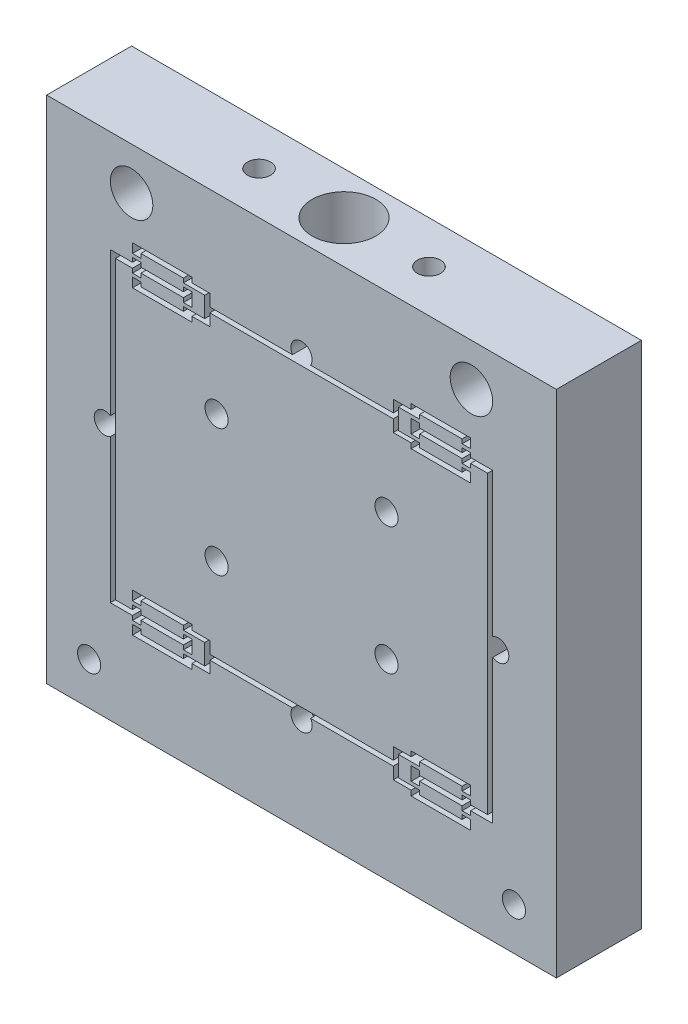
from build123d import *

# Parameters (mm, degrees)
SKETCH1_W                       = 76.2
SKETCH1_H                       = 76.2
BOSS_EXTRUDE1_DEPTH             = 6.35
CUT_EXTRUDE1_DEPTH              = 12.7
CUT_EXTRUDE2_DEPTH              = 12.7
F_1_4_0_25_DIAMETER_HOLE1_D     = 6.35
F_1_4_0_25_DIAMETER_HOLE1_DEPTH = 12.7
F_8_32_TAPPED_HOLE1_D           = 3.4544
F_8_32_TAPPED_HOLE1_DEPTH       = 12.7
SKETCH12_R                      = 3.81
CUT_EXTRUDE7_DEPTH              = 20.828
F_8_32_TAPPED_HOLE2_AT_2_COUNT  = 2
F_8_32_TAPPED_HOLE2_AT_2_PITCH  = 25.4
SKETCH16_R                      = 1.5875
CUT_EXTRUDE8_DEPTH              = 13.7
SKETCH17_R                      = 4.7625
CUT_EXTRUDE9_DEPTH              = 12.7


with BuildPart() as part:
    # Sketch1 → Boss-Extrude1 (new body, symmetric)
    with BuildSketch(Plane.XY):
        Rectangle(SKETCH1_W, SKETCH1_H)
    extrude(amount=BOSS_EXTRUDE1_DEPTH, both=True)

    # Sketch2 → Cut-Extrude1 (cut)
    with BuildSketch(Plane.XY.offset(6.35)):
        Polygon((16.383, 23.495), (17.653, 23.495), (17.653, 22.86), (24.003, 22.86), (24.003, 23.495), (25.273, 23.495), (25.273, 22.86), (28.575, 22.86), (28.575, -22.86), (25.273, -22.86), (25.273, -23.495), (24.003, -23.495), (24.003, -22.86), (17.653, -22.86), (17.653, -23.495), (16.383, -23.495), (16.383, -21.463), (17.653, -21.463), (17.653, -22.098), (24.003, -22.098), (24.003, -21.463), (25.273, -21.463), (25.273, -22.098), (27.813, -22.098), (27.813, 22.098), (25.273, 22.098), (25.273, 21.463), (24.003, 21.463), (24.003, 22.098), (17.653, 22.098), (17.653, 21.463), (16.383, 21.463), align=None)
    cut_extrude1 = extrude(amount=-CUT_EXTRUDE1_DEPTH, mode=Mode.SUBTRACT)

    # Mirror1: Cut-Extrude1 across plane
    add(cut_extrude1.mirror(Plane(origin=(0, 0, 0), x_dir=(0, 0, 1), z_dir=(1, 0, 0))), mode=Mode.SUBTRACT)

    # Sketch3 → Cut-Extrude2 (cut)
    with BuildSketch(Plane.XY.offset(6.35)):
        Polygon((25.273, 20.955), (25.273, 19.558), (16.383, 19.558), (16.383, 20.32), (13.716, 20.32), (13.716, 22.098), (-13.716, 22.098), (-13.716, 20.32), (-16.383, 20.32), (-16.383, 19.558), (-25.273, 19.558), (-25.273, 20.955), (-24.003, 20.955), (-24.003, 20.32), (-17.653, 20.32), (-17.653, 20.955), (-14.478, 20.955), (-14.478, 24.003), (-17.653, 24.003), (-17.653, 24.638), (-24.003, 24.638), (-24.003, 24.003), (-25.273, 24.003), (-25.273, 25.4), (-16.383, 25.4), (-16.383, 24.638), (-13.716, 24.638), (-13.716, 22.86), (13.716, 22.86), (13.716, 24.638), (16.383, 24.638), (16.383, 25.4), (25.273, 25.4), (25.273, 24.003), (24.003, 24.003), (24.003, 24.638), (17.653, 24.638), (17.653, 24.003), (14.478, 24.003), (14.478, 20.955), (17.653, 20.955), (17.653, 20.32), (24.003, 20.32), (24.003, 20.955), align=None)
    cut_extrude2 = extrude(amount=-CUT_EXTRUDE2_DEPTH, mode=Mode.SUBTRACT)

    # Mirror2: Cut-Extrude2 across plane
    add(cut_extrude2.mirror(Plane.ZX), mode=Mode.SUBTRACT)

    # 1/4 (0.25) Diameter Hole1
    with Locations(Plane.XY.offset(6.35)):
        with Locations((-25.4, 31.75), (25.4, 31.75)):
            Hole(F_1_4_0_25_DIAMETER_HOLE1_D / 2, depth=F_1_4_0_25_DIAMETER_HOLE1_DEPTH)

    # #8-32 Tapped Hole1
    with Locations(Plane.XY.offset(6.35)):
        with Locations((-12.7, 9.525), (12.7, 9.525), (12.7, -9.525), (-12.7, -9.525), (-31.75, -31.75), (31.75, -31.75)):
            Hole(F_8_32_TAPPED_HOLE1_D / 2, depth=F_8_32_TAPPED_HOLE1_DEPTH)

    # Sketch12 → Cut-Extrude7 (cut)
    with BuildSketch(Plane(origin=(0, 38.1, 0), x_dir=(1, 0, 0), z_dir=(0, 1, 0))):
        Circle(SKETCH12_R)
    cut_extrude7 = extrude(amount=-CUT_EXTRUDE7_DEPTH, mode=Mode.SUBTRACT)

    # Sketch14 → #8-32 Tapped Hole2 (revolve, cut)
    with BuildSketch(Plane(origin=(-12.7, 38.1, 0), x_dir=(0, 0, 1), z_dir=(1, 0, 0))):
        Polygon((0, 0), (0, 11.197806461), (1.7272, 10.16), (1.7272, 0), align=None)
    f_8_32_tapped_hole2 = revolve(axis=Axis((-12.7, 44.45, 0), (0, -1, 0)), mode=Mode.SUBTRACT)

    # #8-32 Tapped Hole2 at 2: #8-32 Tapped Hole2 ×2
    with Locations(*[(i * F_8_32_TAPPED_HOLE2_AT_2_PITCH, 0, 0) for i in range(1, F_8_32_TAPPED_HOLE2_AT_2_COUNT)]):
        add(f_8_32_tapped_hole2, mode=Mode.SUBTRACT)

    # Mirror4: #8-32 Tapped Hole2, Cut-Extrude7 across plane
    add(f_8_32_tapped_hole2.mirror(Plane.ZX), mode=Mode.SUBTRACT)
    add(cut_extrude7.mirror(Plane.ZX), mode=Mode.SUBTRACT)

    # Mirror4 copy 1 sketch → Mirror4 copy 1 (revolve, cut)
    with BuildSketch(Plane(origin=(12.7, -38.1, 0), x_dir=(0, 0, 1), z_dir=(1, 0, 0))):
        Polygon((0, 0), (0, -11.197806461), (1.7272, -10.16), (1.7272, 0), align=None)
    revolve(axis=Axis((12.7, -44.45, 0), (0, -1, 0)), mode=Mode.SUBTRACT)

    # Sketch16 → Cut-Extrude8 (cut, through all)
    with BuildSketch(Plane.XY.offset(6.35)):
        with Locations((0, 23.6855)):
            Circle(SKETCH16_R)
        with Locations((29.4005, 0)):
            Circle(SKETCH16_R)
        with Locations((-29.4005, 0)):
            Circle(SKETCH16_R)
        with Locations((0, -23.6855)):
            Circle(SKETCH16_R)
    extrude(amount=-CUT_EXTRUDE8_DEPTH, mode=Mode.SUBTRACT)

    # Sketch17 → Cut-Extrude9 (cut)
    with BuildSketch(Plane(origin=(0, 38.1, 0), x_dir=(1, 0, 0), z_dir=(0, 1, 0))):
        Circle(SKETCH17_R)
    cut_extrude9 = extrude(amount=-CUT_EXTRUDE9_DEPTH, mode=Mode.SUBTRACT)

    # Mirror5: Cut-Extrude9 across plane
    add(cut_extrude9.mirror(Plane.ZX), mode=Mode.SUBTRACT)


solid = part.part
